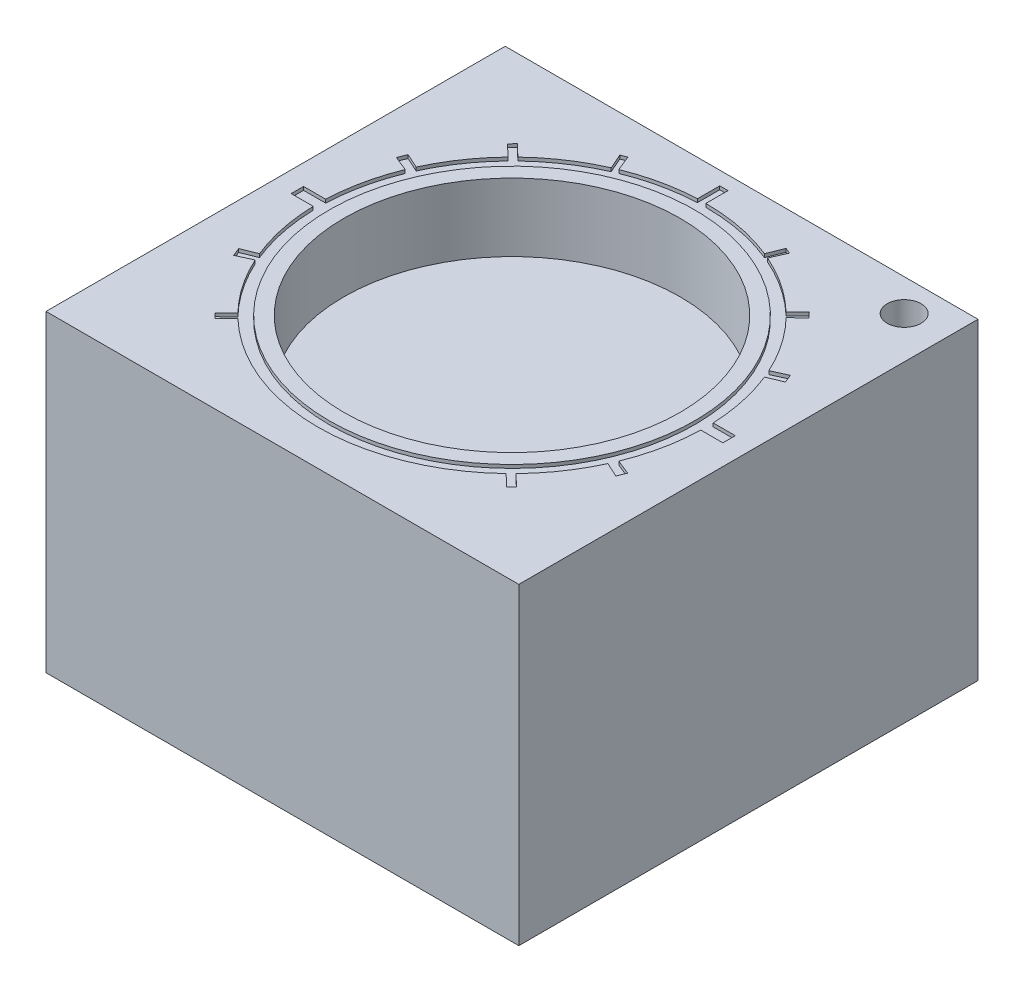
from build123d import *

# Parameters (mm, degrees)
SKETCH1_W           = 6.95
SKETCH1_H           = 6.75
BOSS_EXTRUDE1_DEPTH = 4.6
SKETCH3_3_R         = 2.685665185
CUT_EXTRUDE3_DEPTH  = 0.05
SKETCH3_4_R         = 2.471595258
CUT_EXTRUDE4_DEPTH  = 1
SKETCH3_R           = 0.249549506
CUT_EXTRUDE5_DEPTH  = 0.5


with BuildPart() as part:
    # Sketch1 → Boss-Extrude1 (new body)
    with BuildSketch(Plane(origin=(0, 0, 0), x_dir=(1, 0, 0), z_dir=(0, 1, 0))):
        with Locations((-3.475, 3.375)):
            Rectangle(SKETCH1_W, SKETCH1_H)
    extrude(amount=BOSS_EXTRUDE1_DEPTH)

    # Sketch3_3 → Cut-Extrude3 (cut)
    with BuildSketch(Plane(origin=(0, 4.6, 0), x_dir=(1, 0, 0), z_dir=(0, 1, 0))):
        with BuildLine():
            Line((-2.404106083, 6.015623034), (-2.312667033, 6.241094539))
            Line((-2.312667033, 6.241094539), (-2.227566093, 6.2065822))
            Line((-2.227566093, 6.2065822), (-2.326206207, 5.982676477))
            ThreePointArc((-2.326206207, 5.982676477), (-1.890758445, 5.743519048), (-1.50346617, 5.432366798))
            Line((-1.50346617, 5.432366798), (-1.330630635, 5.60014662))
            Line((-1.330630635, 5.60014662), (-1.258910519, 5.52626536))
            Line((-1.258910519, 5.52626536), (-1.430410767, 5.359781765))
            ThreePointArc((-1.430410767, 5.359781765), (-1.122158532, 4.982432988), (-0.882700889, 4.558084573))
            Line((-0.882700889, 4.558084573), (-0.665701499, 4.657119684))
            Line((-0.665701499, 4.657119684), (-0.615961925, 4.534471247))
            Line((-0.615961925, 4.534471247), (-0.834376966, 4.445893916))
            ThreePointArc((-0.834376966, 4.445893916), (-0.689137564, 3.973894209), (-0.627572536, 3.483906499))
            Line((-0.627572536, 3.483906499), (-0.302033066, 3.483906499))
            Line((-0.302033066, 3.483906499), (-0.302033066, 3.301563496))
            Line((-0.302033066, 3.301563496), (-0.626437053, 3.301563496))
            ThreePointArc((-0.626437053, 3.301563496), (-0.685462224, 2.793465152), (-0.834376966, 2.304106084))
            Line((-0.834376966, 2.304106084), (-0.615961925, 2.215528753))
            Line((-0.615961925, 2.215528753), (-0.665701499, 2.092880316))
            Line((-0.665701499, 2.092880316), (-0.882700889, 2.191915427))
            ThreePointArc((-0.882700889, 2.191915427), (-1.122158532, 1.767567012), (-1.430410767, 1.390218235))
            Line((-1.430410767, 1.390218235), (-1.258910519, 1.22373464))
            Line((-1.258910519, 1.22373464), (-1.330630635, 1.14985338))
            Line((-1.330630635, 1.14985338), (-1.50346617, 1.317633202))
            ThreePointArc((-1.50346617, 1.317633202), (-3.475, 0.525490606), (-5.44653383, 1.317633202))
            Line((-5.44653383, 1.317633202), (-5.619369365, 1.14985338))
            Line((-5.619369365, 1.14985338), (-5.691089481, 1.22373464))
            Line((-5.691089481, 1.22373464), (-5.519589233, 1.390218235))
            ThreePointArc((-5.519589233, 1.390218235), (-5.827841468, 1.767567012), (-6.067299111, 2.191915427))
            Line((-6.067299111, 2.191915427), (-6.284298501, 2.092880316))
            Line((-6.284298501, 2.092880316), (-6.334038075, 2.215528753))
            Line((-6.334038075, 2.215528753), (-6.115623034, 2.304106084))
            ThreePointArc((-6.115623034, 2.304106084), (-6.264537776, 2.793465152), (-6.323562947, 3.301563496))
            Line((-6.323562947, 3.301563496), (-6.647966934, 3.301563496))
            Line((-6.647966934, 3.301563496), (-6.647966934, 3.483906499))
            Line((-6.647966934, 3.483906499), (-6.322427464, 3.483906499))
            ThreePointArc((-6.322427464, 3.483906499), (-6.260862436, 3.973894209), (-6.115623034, 4.445893916))
            Line((-6.115623034, 4.445893916), (-6.334038075, 4.534471247))
            Line((-6.334038075, 4.534471247), (-6.284298501, 4.657119684))
            Line((-6.284298501, 4.657119684), (-6.067299111, 4.558084573))
            ThreePointArc((-6.067299111, 4.558084573), (-5.827841468, 4.982432988), (-5.519589233, 5.359781765))
            Line((-5.519589233, 5.359781765), (-5.691089481, 5.52626536))
            Line((-5.691089481, 5.52626536), (-5.619369365, 5.60014662))
            Line((-5.619369365, 5.60014662), (-5.44653383, 5.432366798))
            ThreePointArc((-5.44653383, 5.432366798), (-5.059241555, 5.743519048), (-4.623793793, 5.982676477))
            Line((-4.623793793, 5.982676477), (-4.722433907, 6.2065822))
            Line((-4.722433907, 6.2065822), (-4.637332967, 6.241094539))
            Line((-4.637332967, 6.241094539), (-4.545893917, 6.015623034))
            ThreePointArc((-4.545893917, 6.015623034), (-4.079985397, 6.159546005), (-3.596359951, 6.221923875))
            Line((-3.596359951, 6.221923875), (-3.596359951, 6.550048868))
            Line((-3.596359951, 6.550048868), (-3.475, 6.550048868))
            Line((-3.475, 6.550048868), (-3.475, 6.224509394))
            ThreePointArc((-3.475, 6.224509394), (-2.929461896, 6.171800308), (-2.404106083, 6.015623034))
        make_face()
        with Locations((-3.475, 3.375)):
            Circle(SKETCH3_3_R, mode=Mode.SUBTRACT)
    extrude(amount=-CUT_EXTRUDE3_DEPTH, mode=Mode.SUBTRACT)

    # Sketch3_4 → Cut-Extrude4 (cut)
    with BuildSketch(Plane(origin=(0, 4.6, 0), x_dir=(1, 0, 0), z_dir=(0, 1, 0))):
        with Locations((-3.475, 3.375)):
            Circle(SKETCH3_4_R)
    extrude(amount=-CUT_EXTRUDE4_DEPTH, mode=Mode.SUBTRACT)

    # Sketch3 → Cut-Extrude5 (cut)
    with BuildSketch(Plane(origin=(0, 4.6, 0), x_dir=(1, 0, 0), z_dir=(0, 1, 0))):
        with Locations((-0.615961925, 6.280685908)):
            Circle(SKETCH3_R)
    extrude(amount=-CUT_EXTRUDE5_DEPTH, mode=Mode.SUBTRACT)


solid = part.part
